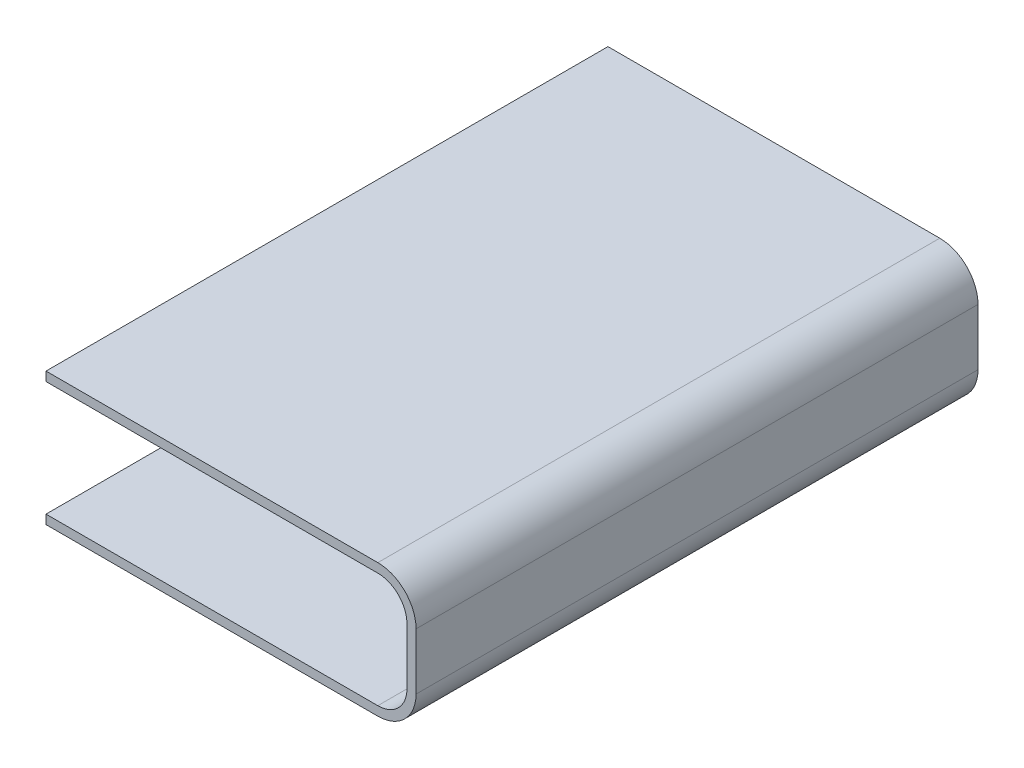
from build123d import *

# Parameters (mm, degrees)
SKETCH3_W                       = 304.8
SKETCH3_H                       = 0.79375
BOSS_EXTRUDE1_DEPTH             = 152.4
BOSS_EXTRUDE1_DEPTH_BACK        = 152.4
SKETCH4_OUTSIDE_W               = 393.01
SKETCH4_OUTSIDE_H               = 393.01
SKETCH4_OUTSIDE_W_2             = 28.9306
SKETCH4_OUTSIDE_H_2             = 48.9966
CUT_EXTRUDE1_DEPTH              = 1.396875
CUT_EXTRUDE1_DEPTH_BACK         = 1.396875
EXTRUDE_THIN1_REACH             = 26.498
EXTRUDE_THIN1_DIRECTION_2_REACH = 26.498


with BuildPart() as part:
    # Sketch3 → Boss-Extrude1 (new body, two sides)
    with BuildSketch(Plane.XY) as boss_extrude1_sk:
        Rectangle(SKETCH3_W, SKETCH3_H)
    extrude(amount=BOSS_EXTRUDE1_DEPTH)
    extrude(boss_extrude1_sk.sketch, amount=-BOSS_EXTRUDE1_DEPTH_BACK)

    # Sketch4 outside → Cut-Extrude1 (cut, two sides)
    with BuildSketch(Plane(origin=(0, 0, 0), x_dir=(1, 0, 0), z_dir=(0, 1, 0))) as cut_extrude1_sk:
        Rectangle(SKETCH4_OUTSIDE_W, SKETCH4_OUTSIDE_H)
        with Locations((-137.9347, -127.9017)):
            Rectangle(SKETCH4_OUTSIDE_W_2, SKETCH4_OUTSIDE_H_2, mode=Mode.SUBTRACT)
    extrude(amount=CUT_EXTRUDE1_DEPTH, mode=Mode.SUBTRACT)
    extrude(cut_extrude1_sk.sketch, amount=-CUT_EXTRUDE1_DEPTH_BACK, mode=Mode.SUBTRACT)

    # Extrude-Thin1: up to this face of the body (flat: up to its plane)
    extrude_thin1_end = Plane(part.part.faces().sort_by_distance((-137.9347, 0, 103.4034))[0])
    # Sketch5 → Extrude-Thin1 (add, up to the picked face)
    with BuildSketch(Plane.XY.offset(127.9017), mode=Mode.PRIVATE) as extrude_thin1_sk1:
        with BuildLine():
            Line((-152.4, -10.404475), (-123.4694, -10.404475))
            ThreePointArc((-123.4694, -10.404475), (-121.673348776, -9.660526224), (-120.9294, -7.864475))
            Line((-120.9294, -7.864475), (-120.9294, -2.936875))
            ThreePointArc((-120.9294, -2.936875), (-121.673348776, -1.140823776), (-123.4694, -0.396875))
            Line((-123.4694, -0.396875), (-123.4694, 0.396875))
            ThreePointArc((-123.4694, 0.396875), (-121.112082768, -0.579557768), (-120.13565, -2.936875))
            Line((-120.13565, -2.936875), (-120.13565, -7.864475))
            ThreePointArc((-120.13565, -7.864475), (-121.112082768, -10.221792232), (-123.4694, -11.198225))
            Line((-123.4694, -11.198225), (-152.4, -11.198225))
            Line((-152.4, -11.198225), (-152.4, -10.404475))
        make_face()
    extrude_thin1_tool1 = split(extrude(extrude_thin1_sk1.sketch, amount=-EXTRUDE_THIN1_REACH, mode=Mode.PRIVATE), bisect_by=extrude_thin1_end, keep=Keep.BOTH, mode=Mode.PRIVATE)
    add(extrude_thin1_tool1.solids().sort_by_distance((-137.9347, -10.855379, 127.9017))[0])

    # Extrude-Thin1 direction 2: up to this face of the body (flat: up to its plane)
    extrude_thin1_direction_2_end = Plane(part.part.faces().sort_by_distance((-137.9347, 0, 152.4))[0])
    # Sketch5 → Extrude-Thin1 direction 2 (add, up to the picked face)
    with BuildSketch(Plane.XY.offset(127.9017), mode=Mode.PRIVATE) as extrude_thin1_direction_2_sk1:
        with BuildLine():
            Line((-152.4, -10.404475), (-123.4694, -10.404475))
            ThreePointArc((-123.4694, -10.404475), (-121.673348776, -9.660526224), (-120.9294, -7.864475))
            Line((-120.9294, -7.864475), (-120.9294, -2.936875))
            ThreePointArc((-120.9294, -2.936875), (-121.673348776, -1.140823776), (-123.4694, -0.396875))
            Line((-123.4694, -0.396875), (-123.4694, 0.396875))
            ThreePointArc((-123.4694, 0.396875), (-121.112082768, -0.579557768), (-120.13565, -2.936875))
            Line((-120.13565, -2.936875), (-120.13565, -7.864475))
            ThreePointArc((-120.13565, -7.864475), (-121.112082768, -10.221792232), (-123.4694, -11.198225))
            Line((-123.4694, -11.198225), (-152.4, -11.198225))
            Line((-152.4, -11.198225), (-152.4, -10.404475))
        make_face()
    extrude_thin1_direction_2_tool1 = split(extrude(extrude_thin1_direction_2_sk1.sketch, amount=EXTRUDE_THIN1_DIRECTION_2_REACH, mode=Mode.PRIVATE), bisect_by=extrude_thin1_direction_2_end, keep=Keep.BOTH, mode=Mode.PRIVATE)
    add(extrude_thin1_direction_2_tool1.solids().sort_by_distance((-137.9347, -10.855379, 127.9017))[0])


solid = part.part
